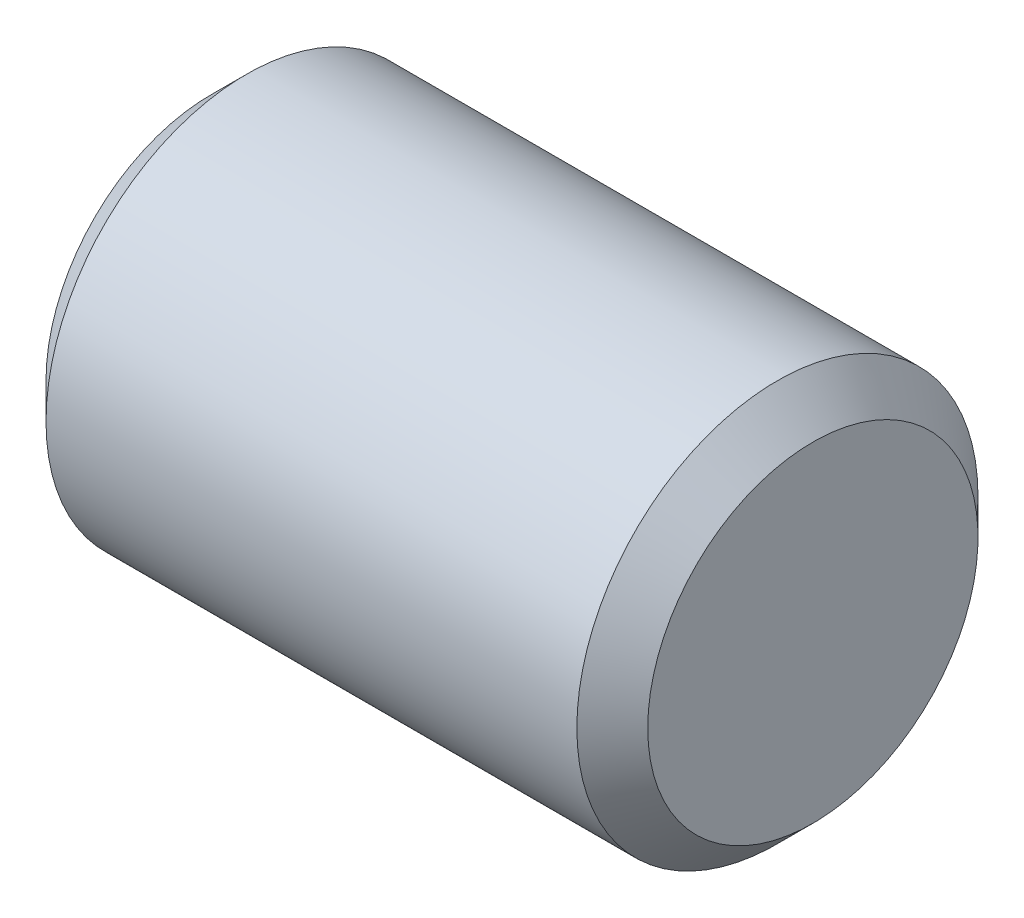
from build123d import *


with BuildPart() as part:
    # Sketch1 → Revolve1 (revolve)
    with BuildSketch(Plane.XY):
        Polygon((-2.863636364, 0), (-2.863636364, -1.646446609), (-2.510082973, -2), (2.782810246, -2), (3.136363636, -1.646446609), (3.136363636, 0), align=None)
    revolve(axis=Axis((-4.965240642, 0, 0), (1, 0, 0)))


solid = part.part
